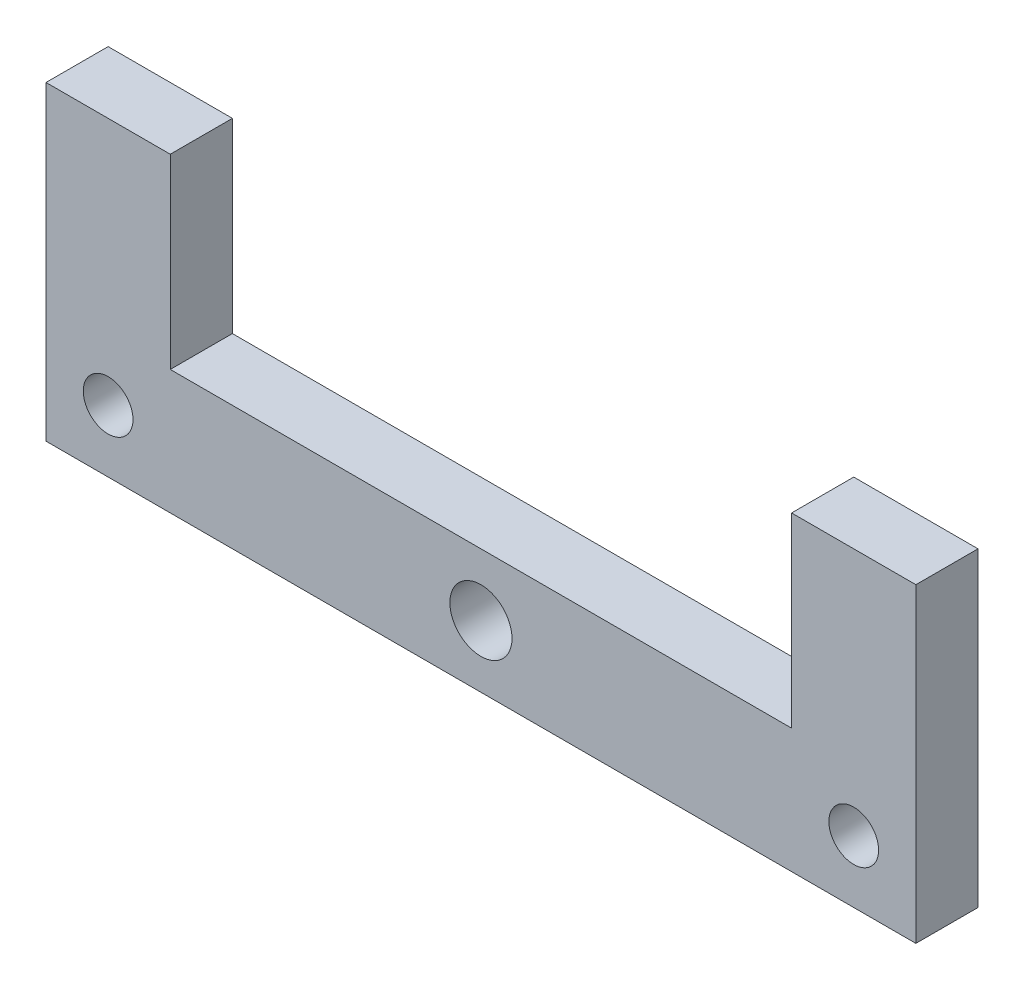
from build123d import *

# Parameters (mm, degrees)
ESQUISSE1_R        = 4
ESQUISSE1_R_2      = 5
BOSS_EXTRU_1_DEPTH = 10


with BuildPart() as part:
    # Esquisse1 → Boss.-Extru.1 (new body)
    with BuildSketch(Plane.XY):
        Polygon((-70, 40), (-70, 10), (-70, -10), (70, -10), (70, 10), (70, 40), (50, 40), (50, 10), (-50, 10), (-50, 40), align=None)
        with Locations((-60, 0)):
            Circle(ESQUISSE1_R, mode=Mode.SUBTRACT)
        Circle(ESQUISSE1_R_2, mode=Mode.SUBTRACT)
        with Locations((60, 0)):
            Circle(ESQUISSE1_R, mode=Mode.SUBTRACT)
        Polygon((-70, 40), (-70, 10), (-70, -10), (70, -10), (70, 10), (70, 40), (50, 40), (50, 10), (-50, 10), (-50, 40), align=None)
        with Locations((-60, 0)):
            Circle(ESQUISSE1_R, mode=Mode.SUBTRACT)
        Circle(ESQUISSE1_R_2, mode=Mode.SUBTRACT)
        with Locations((60, 0)):
            Circle(ESQUISSE1_R, mode=Mode.SUBTRACT)
        Polygon((-70, 40), (-70, 10), (-70, -10), (70, -10), (70, 10), (70, 40), (50, 40), (50, 10), (-50, 10), (-50, 40), align=None)
        with Locations((-60, 0)):
            Circle(ESQUISSE1_R, mode=Mode.SUBTRACT)
        Circle(ESQUISSE1_R_2, mode=Mode.SUBTRACT)
        with Locations((60, 0)):
            Circle(ESQUISSE1_R, mode=Mode.SUBTRACT)
    extrude(amount=BOSS_EXTRU_1_DEPTH)


solid = part.part
